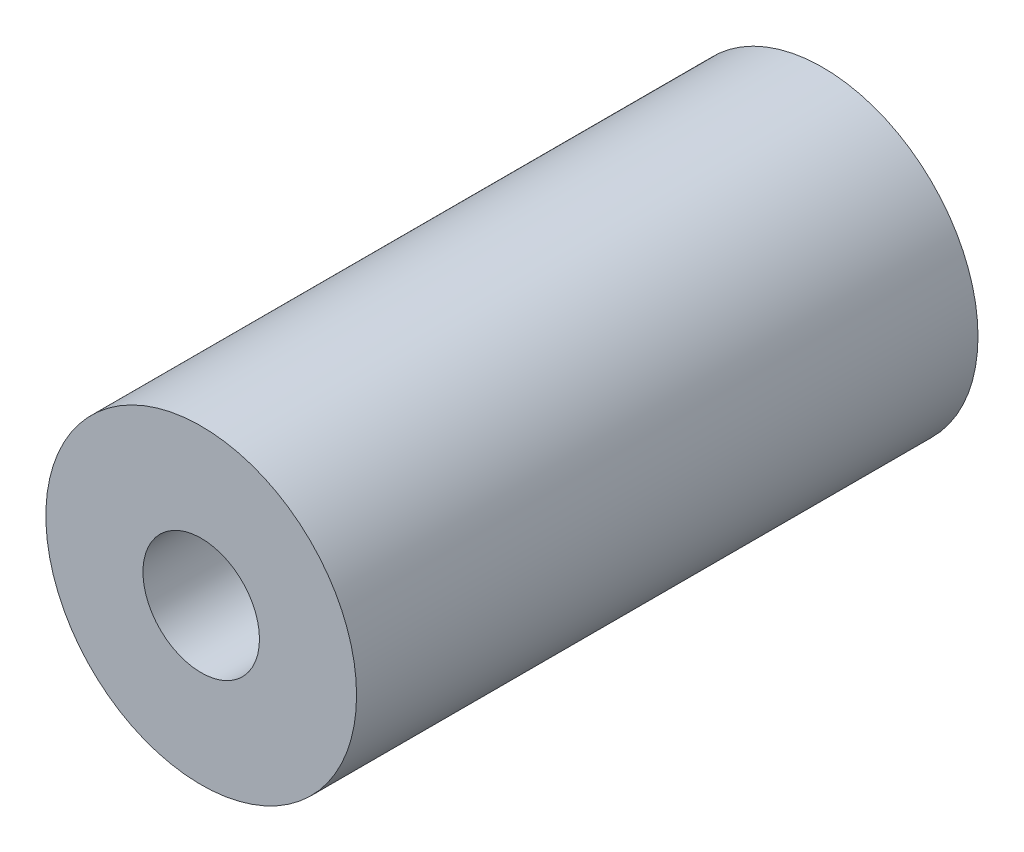
from build123d import *

# Parameters (mm, degrees)
SKETCH1_R           = 4
SKETCH1_R_2         = 1.5
BOSS_EXTRUDE1_DEPTH = 16


with BuildPart() as part:
    # Sketch1 → Boss-Extrude1 (new body)
    with BuildSketch(Plane.XY):
        Circle(SKETCH1_R)
        Circle(SKETCH1_R_2, mode=Mode.SUBTRACT)
    extrude(amount=BOSS_EXTRUDE1_DEPTH)


solid = part.part
